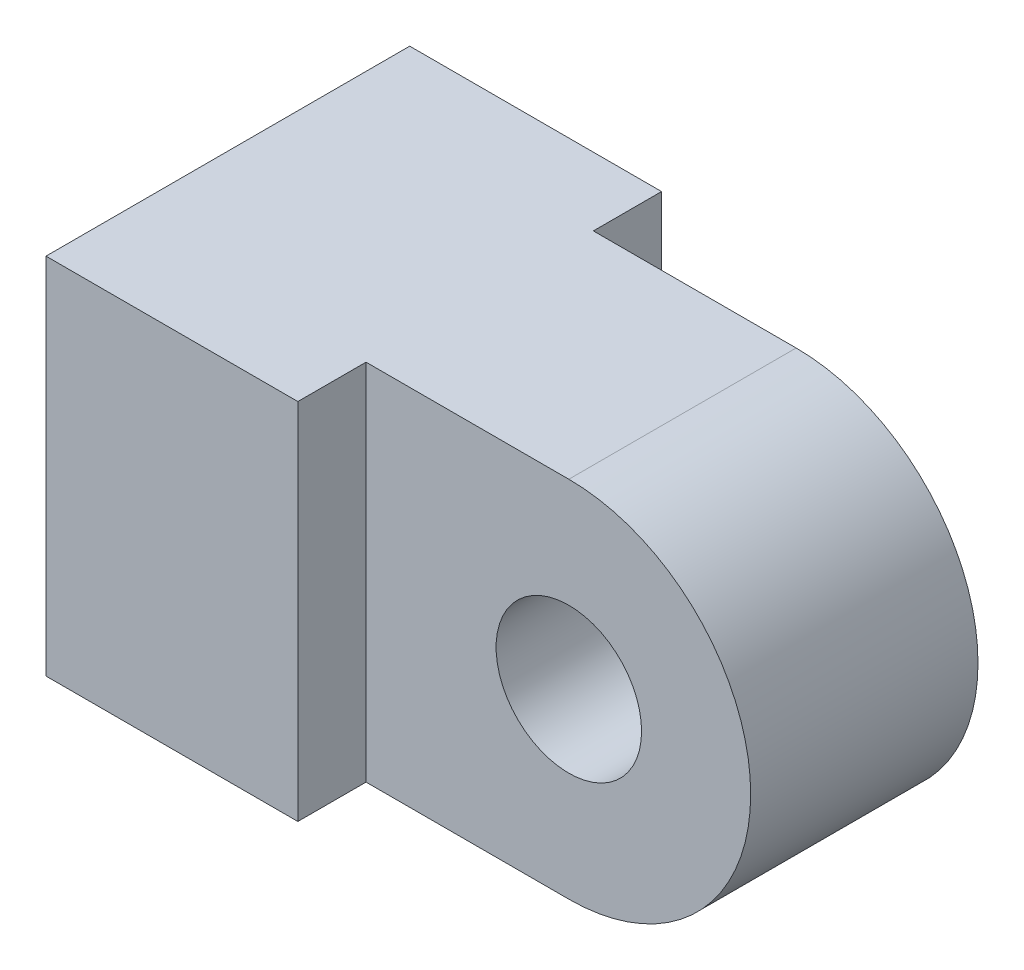
from build123d import *

# Parameters (mm, degrees)
SKETCH1_R           = 1.6
BOSS_EXTRUDE2_DEPTH = 5
SKETCH2_W           = 5.53954597
SKETCH2_H           = 8
BOSS_EXTRUDE3_DEPTH = 1.5
SKETCH3_W           = 5.53954597
SKETCH3_H           = 8
BOSS_EXTRUDE4_DEPTH = 1.5


with BuildPart() as part:
    # Sketch1 → Boss-Extrude2 (new body)
    with BuildSketch(Plane.XY):
        with BuildLine():
            Line((0, 4), (-10, 4))
            Line((-10, 4), (-10, -4))
            Line((-10, -4), (0, -4))
            ThreePointArc((0, -4), (4, 0), (0, 4))
        make_face()
        Circle(SKETCH1_R, mode=Mode.SUBTRACT)
    extrude(amount=BOSS_EXTRUDE2_DEPTH)

    # Sketch2 → Boss-Extrude3 (add)
    with BuildSketch(Plane.XY.offset(5)):
        with Locations((-7.230227015, 0)):
            Rectangle(SKETCH2_W, SKETCH2_H)
    extrude(amount=BOSS_EXTRUDE3_DEPTH)

    # Sketch3 → Boss-Extrude4 (add)
    with BuildSketch(Plane(origin=(0, 0, 0), x_dir=(-1, 0, 0), z_dir=(0, 0, -1))):
        with Locations((7.230227015, 0)):
            Rectangle(SKETCH3_W, SKETCH3_H)
    extrude(amount=BOSS_EXTRUDE4_DEPTH)


solid = part.part
